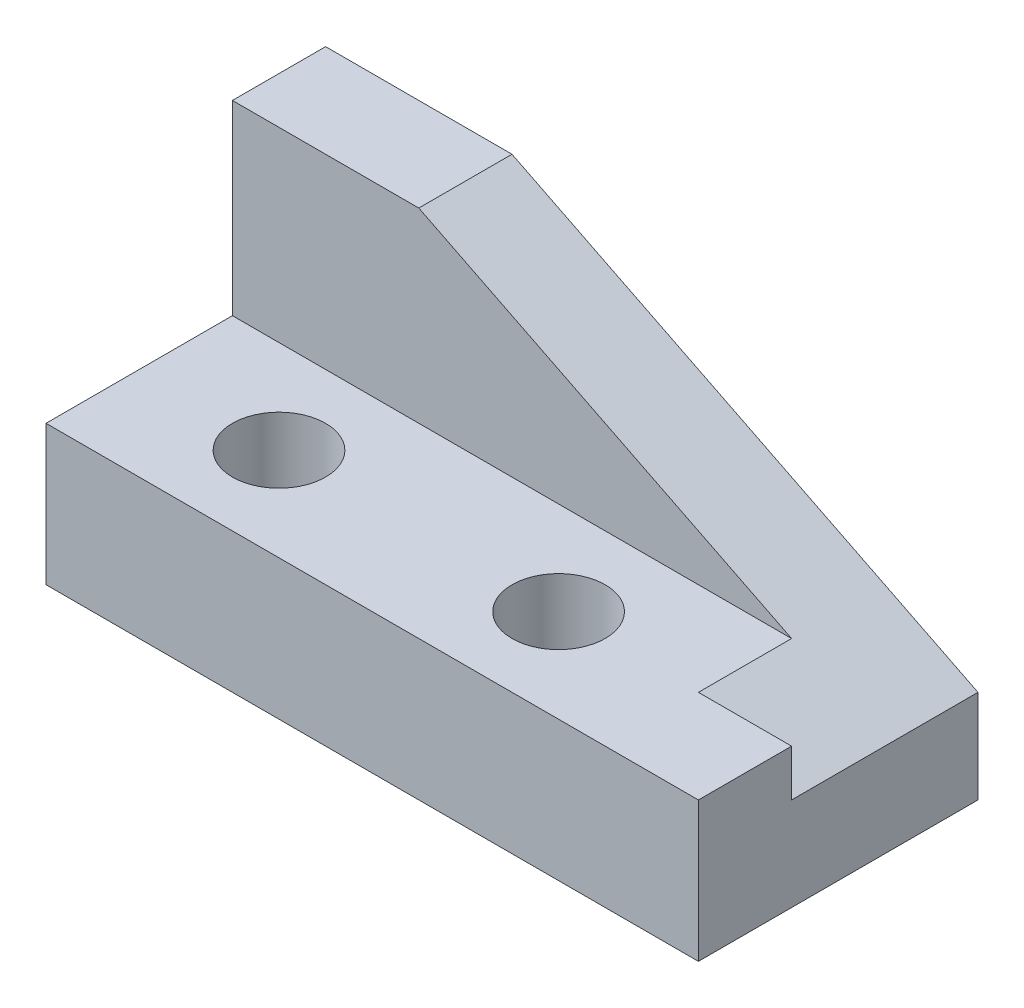
from build123d import *

# Parameters (mm, degrees)
SKETCH1_W           = 70
SKETCH1_H           = 30
BOSS_EXTRUDE1_DEPTH = 35
CUT_EXTRUDE1_DEPTH  = 20
SKETCH3_W           = 20
SKETCH3_H           = 20
CUT_EXTRUDE2_DEPTH  = 71
SKETCH4_R           = 5
CUT_EXTRUDE3_DEPTH  = 16
SKETCH5_R           = 5
CUT_EXTRUDE4_DEPTH  = 16


with BuildPart() as part:
    # Sketch1 → Boss-Extrude1 (new body)
    with BuildSketch(Plane(origin=(0, 0, 0), x_dir=(1, 0, 0), z_dir=(0, 1, 0))):
        with Locations((35, 15)):
            Rectangle(SKETCH1_W, SKETCH1_H)
    extrude(amount=BOSS_EXTRUDE1_DEPTH)

    # Sketch2 → Cut-Extrude1 (cut)
    with BuildSketch(Plane(origin=(0, 0, -30), x_dir=(-1, 0, 0), z_dir=(0, 0, -1))):
        Polygon((-70, 35), (-70, 10), (-20, 35), align=None)
    extrude(amount=-CUT_EXTRUDE1_DEPTH, mode=Mode.SUBTRACT)

    # Sketch3 → Cut-Extrude2 (cut, through all)
    with BuildSketch(Plane.ZY):
        with Locations((-10, 25)):
            Rectangle(SKETCH3_W, SKETCH3_H)
    extrude(amount=-CUT_EXTRUDE2_DEPTH, mode=Mode.SUBTRACT)

    # Sketch4 → Cut-Extrude3 (cut, through all)
    with BuildSketch(Plane(origin=(0, 15, 0), x_dir=(1, 0, 0), z_dir=(0, 1, 0))):
        with Locations((15, 10)):
            Circle(SKETCH4_R)
    extrude(amount=-CUT_EXTRUDE3_DEPTH, mode=Mode.SUBTRACT)

    # Sketch5 → Cut-Extrude4 (cut, through all)
    with BuildSketch(Plane(origin=(0, 15, 0), x_dir=(1, 0, 0), z_dir=(0, 1, 0))):
        with Locations((45, 10)):
            Circle(SKETCH5_R)
    extrude(amount=-CUT_EXTRUDE4_DEPTH, mode=Mode.SUBTRACT)


solid = part.part
